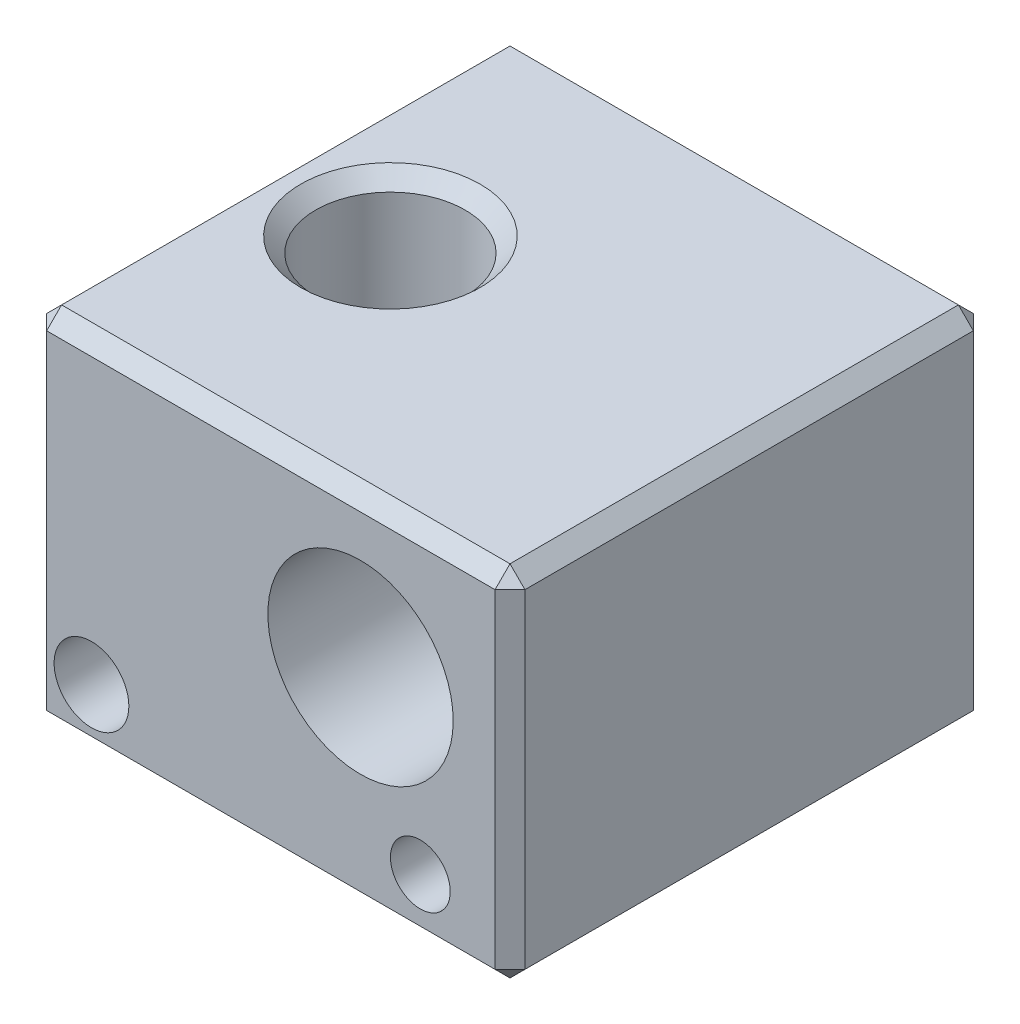
from build123d import *

# Parameters (mm, degrees)
SKETCH1_W                       = 16
SKETCH1_H                       = 16
BOSS_EXTRUDE1_DEPTH             = 12
SKETCH2_R                       = 3.1
SKETCH2_R_2                     = 1
CUT_EXTRUDE1_DEPTH              = 17
F_2_5_2_5_DIAMETER_HOLE1_D      = 2.5
F_2_5_2_5_DIAMETER_HOLE1_DEPTH  = 4.5
TAP_DRILL_FOR_M6X1_0_TAP1_D     = 5
TAP_DRILL_FOR_M3X0_5_TAP1_D     = 2.5
TAP_DRILL_FOR_M3X0_5_TAP1_DEPTH = 6.999
TAP_DRILL_FOR_M3X0_5_TAP1_TIP   = 0.751075774
CHAMFER1_SIZE                   = 0.5


with BuildPart() as part:
    # Sketch1 → Boss-Extrude1 (new body)
    with BuildSketch(Plane(origin=(0, 0, 0), x_dir=(1, 0, 0), z_dir=(0, 1, 0))):
        Rectangle(SKETCH1_W, SKETCH1_H)
    extrude(amount=BOSS_EXTRUDE1_DEPTH)

    # Sketch2 → Cut-Extrude1 (cut, through all)
    with BuildSketch(Plane.XY.offset(8)):
        with Locations((3, 7)):
            Circle(SKETCH2_R)
        with Locations((5, 2)):
            Circle(SKETCH2_R_2)
    extrude(amount=-CUT_EXTRUDE1_DEPTH, mode=Mode.SUBTRACT)

    # Ø2.5 (2.5) Diameter Hole1
    with Locations(Plane.XY.offset(8)):
        with Locations((-6, 2)):
            Hole(F_2_5_2_5_DIAMETER_HOLE1_D / 2, depth=F_2_5_2_5_DIAMETER_HOLE1_DEPTH)

    # Tap Drill for M6x1.0 Tap1 (through all)
    with Locations(Plane(origin=(0, 12, 0), x_dir=(1, 0, 0), z_dir=(0, 1, 0))):
        with Locations((-4, 0)):
            Hole(TAP_DRILL_FOR_M6X1_0_TAP1_D / 2)

    # Tap Drill for M3x0.5 Tap1
    with Locations(Plane(origin=(0, 0, 0), x_dir=(-1, 0, 0), z_dir=(0, -1, 0))):
        with Locations((-2, 0)):
            Hole(TAP_DRILL_FOR_M3X0_5_TAP1_D / 2, depth=TAP_DRILL_FOR_M3X0_5_TAP1_DEPTH)
            with Locations((0, 0, -(TAP_DRILL_FOR_M3X0_5_TAP1_DEPTH + TAP_DRILL_FOR_M3X0_5_TAP1_TIP / 2))):  # 118° drill point
                Cone(0, TAP_DRILL_FOR_M3X0_5_TAP1_D / 2, TAP_DRILL_FOR_M3X0_5_TAP1_TIP, mode=Mode.SUBTRACT)

    # Chamfer1
    chamfer1_edges = [part.edges().sort_by_distance(p)[0] for p in [
        (0, 12, -8),
        (-8, 12, 0),
        (-1.5, 12, 0),
        (-1.5, 0, 0),
        (0.75, 0, 0),
        (0, 12, 8),
        (-8, 0, 0),
        (0, 0, -8),
        (8, 0, 0),
        (0, 0, 8),
        (8, 12, 0),
        (-8, 6, 8),
        (-8, 6, -8),
        (8, 6, -8),
        (8, 6, 8),
    ]]
    chamfer(chamfer1_edges, length=CHAMFER1_SIZE)


solid = part.part
